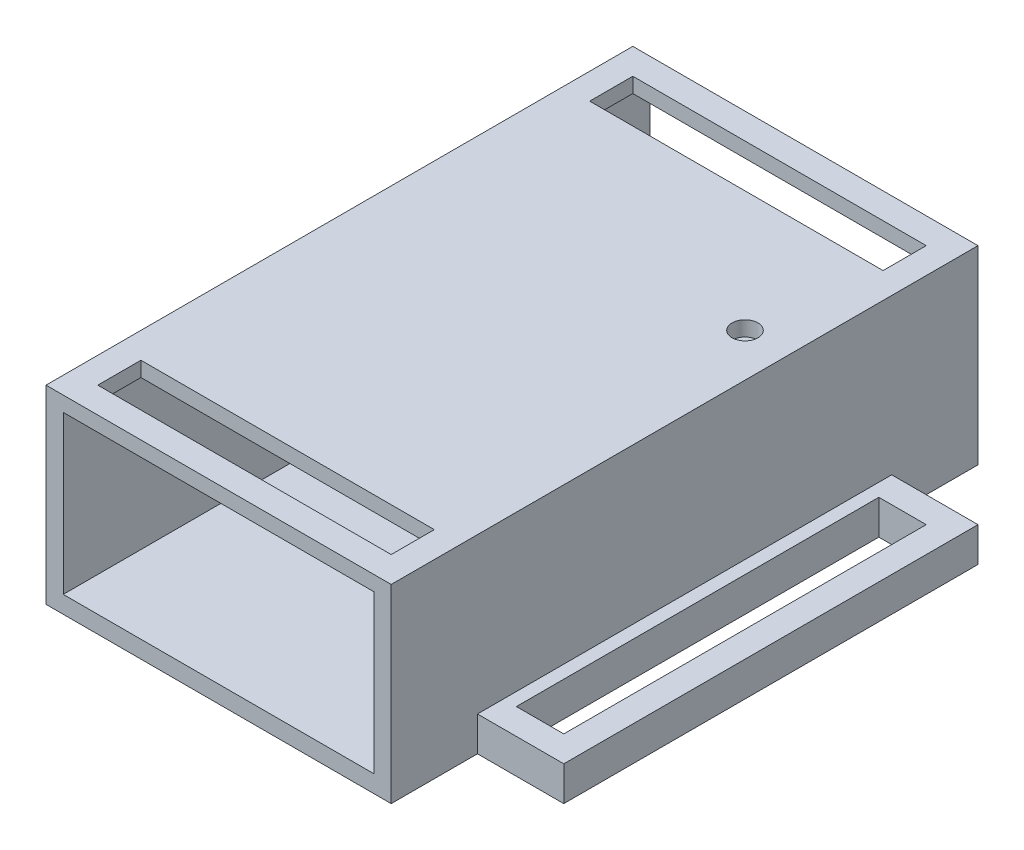
from build123d import *

# Parameters (mm, degrees)
SKETCH1_W           = 40
SKETCH1_H           = 68
SKETCH1_R           = 1.5
BOSS_EXTRUDE1_DEPTH = 22
SKETCH2_W           = 36
SKETCH2_H           = 18.265871498
CUT_EXTRUDE1_DEPTH  = 69
SKETCH3_W           = 34
SKETCH3_H           = 5
CUT_EXTRUDE2_DEPTH  = 2
SKETCH6_W           = 48
SKETCH6_H           = 4
BOSS_EXTRUDE3_DEPTH = 10
SKETCH7_W           = 5.490890851
SKETCH7_H           = 42
CUT_EXTRUDE4_DEPTH  = 10


with BuildPart() as part:
    # Sketch1 → Boss-Extrude1 (new body)
    with BuildSketch(Plane(origin=(0, 0, 0), x_dir=(1, 0, 0), z_dir=(0, 1, 0))):
        with Locations((20, -34)):
            Rectangle(SKETCH1_W, SKETCH1_H)
        with Locations((35, -22)):
            Circle(SKETCH1_R, mode=Mode.SUBTRACT)
    extrude(amount=BOSS_EXTRUDE1_DEPTH)

    # Sketch2 → Cut-Extrude1 (cut, through all)
    with BuildSketch(Plane.XY.offset(68)):
        with Locations((20, 11.132935749)):
            Rectangle(SKETCH2_W, SKETCH2_H)
    extrude(amount=-CUT_EXTRUDE1_DEPTH, mode=Mode.SUBTRACT)

    # Sketch3 → Cut-Extrude2 (cut)
    with BuildSketch(Plane(origin=(0, 22, 0), x_dir=(1, 0, 0), z_dir=(0, 1, 0))):
        with Locations((20, -62.5)):
            Rectangle(SKETCH3_W, SKETCH3_H)
        with Locations((20, -5.5)):
            Rectangle(SKETCH3_W, SKETCH3_H)
    extrude(amount=-CUT_EXTRUDE2_DEPTH, mode=Mode.SUBTRACT)

    # Sketch6 → Boss-Extrude3 (add)
    with BuildSketch(Plane(origin=(40, 0, 0), x_dir=(0, 0, -1), z_dir=(1, 0, 0))):
        with Locations((-34, 2)):
            Rectangle(SKETCH6_W, SKETCH6_H)
    boss_extrude3 = extrude(amount=BOSS_EXTRUDE3_DEPTH)

    # Sketch7 → Cut-Extrude4 (cut)
    with BuildSketch(Plane(origin=(0, 4, 0), x_dir=(1, 0, 0), z_dir=(0, 1, 0))):
        with Locations((44.254554575, -34)):
            Rectangle(SKETCH7_W, SKETCH7_H)
    cut_extrude4 = extrude(amount=-CUT_EXTRUDE4_DEPTH, mode=Mode.SUBTRACT)

    # Mirror1: Boss-Extrude3 across plane
    add(boss_extrude3.mirror(Plane(origin=(20, 0, 0), x_dir=(0, 0, 1), z_dir=(1, 0, 0))))

    # Mirror2: Cut-Extrude4 across plane
    add(cut_extrude4.mirror(Plane(origin=(20, 0, 0), x_dir=(0, 0, 1), z_dir=(1, 0, 0))), mode=Mode.SUBTRACT)


solid = part.part
